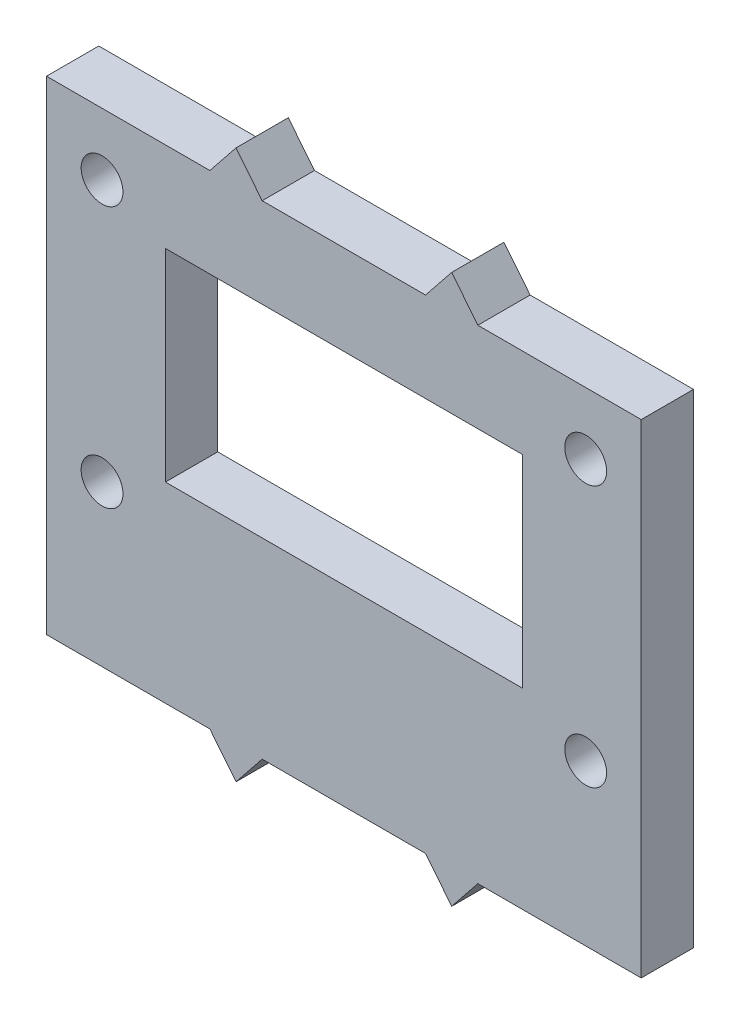
from build123d import *

# Parameters (mm, degrees)
SKETCH1_W              = 45.5
SKETCH1_H              = 37
BASIS_DEPTH            = 4
SKETCH6_W              = 27.3
SKETCH6_H              = 15.480915405
SHOW_ONLY_SCREEN_DEPTH = 10.04
SKETCH11_R             = 1.6
CUT_EXTRUDE10_DEPTH    = 4


with BuildPart() as part:
    # Sketch1 → Basis (new body)
    with BuildSketch(Plane.XY):
        with Locations((22.75, 18.5)):
            Rectangle(SKETCH1_W, SKETCH1_H)
        Polygon((14.5, 39.5), (12.5, 37), (16.5, 37), align=None)
        Polygon((31, 39.5), (29, 37), (33, 37), align=None)
        Polygon((16.5, 0), (12.5, 0), (14.5, -2.5), align=None)
        Polygon((33, 0), (29, 0), (31, -2.5), align=None)
    extrude(amount=BASIS_DEPTH)

    # Sketch6 → Show only screen (cut)
    with BuildSketch(Plane.XY.offset(4)):
        with Locations((22.75, 22.399542298)):
            Rectangle(SKETCH6_W, SKETCH6_H)
    extrude(amount=-SHOW_ONLY_SCREEN_DEPTH, mode=Mode.SUBTRACT)

    # Sketch11 → Cut-Extrude10 (cut)
    with BuildSketch(Plane(origin=(0, 0, 0), x_dir=(-1, 0, 0), z_dir=(0, 0, -1))):
        with Locations((-41.25, 32.252592082)):
            Circle(SKETCH11_R)
        with Locations((-4.25, 32.252592082)):
            Circle(SKETCH11_R)
        with Locations((-4.25, 12.252592082)):
            Circle(SKETCH11_R)
        with Locations((-41.25, 12.252592082)):
            Circle(SKETCH11_R)
    extrude(amount=-CUT_EXTRUDE10_DEPTH, mode=Mode.SUBTRACT)


solid = part.part
